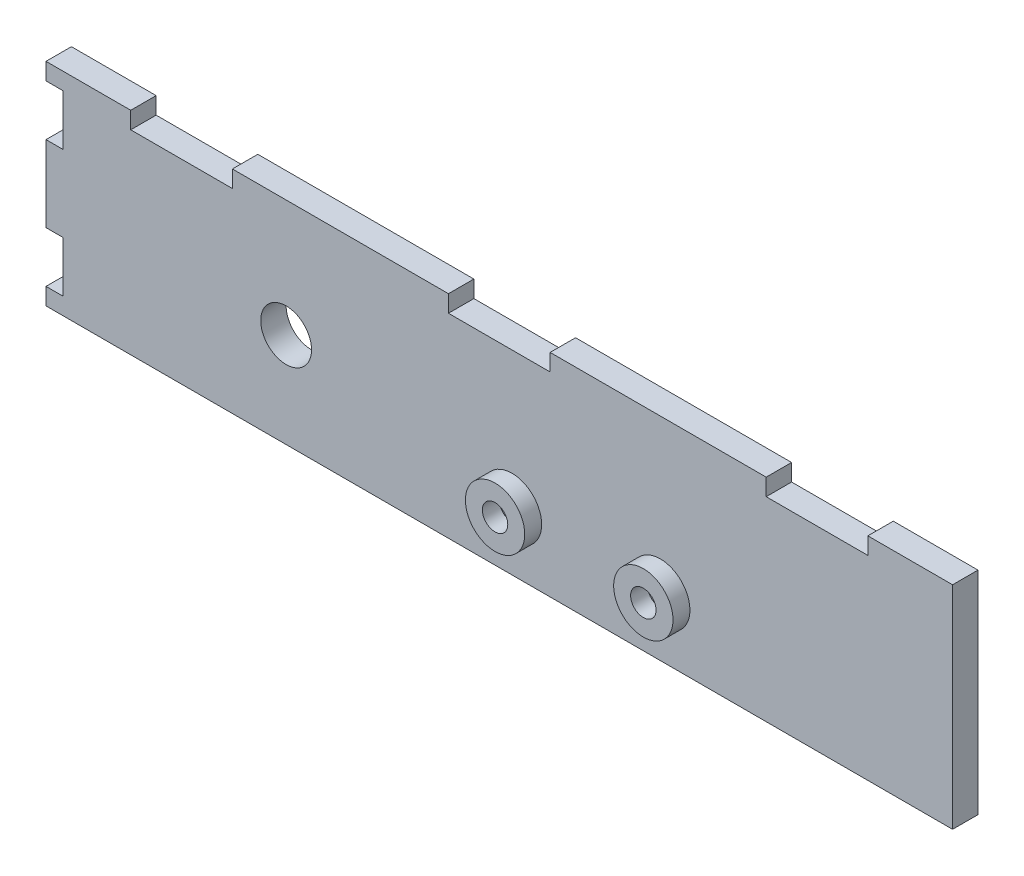
from build123d import *

# Parameters (mm, degrees)
ESBO_O1_R                = 3
ESBO_O1_R_2              = 1.5
RESSALTO_EXTRUS_O1_DEPTH = 3
ESBO_O1_19_R             = 3.5
ESBO_O1_19_R_2           = 1.5
RESSALTO_EXTRUS_O2_DEPTH = 5
ESBO_O1_20_R             = 1.5
RESSALTO_EXTRUS_O3_DEPTH = 3


with BuildPart() as part:
    # Esboço1 → Ressalto-extrusão1 (new body)
    with BuildSketch(Plane.XY):
        Polygon((-30.67768595, 33.271694215), (-40.67768595, 33.271694215), (-40.67768595, 31.271694215), (-38.67768595, 31.271694215), (-38.67768595, 25.271694215), (-40.67768595, 25.271694215), (-40.67768595, 16.271694215), (-38.67768595, 16.271694215), (-38.67768595, 10.271694215), (-40.67768595, 10.271694215), (-40.67768595, 8.271694215), (66.32231405, 8.271694215), (66.32231405, 33.271694215), (56.32231405, 33.271694215), (56.32231405, 31.271694215), (44.32231405, 31.271694215), (44.32231405, 33.271694215), (18.82231405, 33.271694215), (18.82231405, 31.271694215), (6.82231405, 31.271694215), (6.82231405, 33.271694215), (-18.67768595, 33.271694215), (-18.67768595, 31.271694215), (-30.67768595, 31.271694215), align=None)
        with Locations((-12.336122998, 19.452784517)):
            Circle(ESBO_O1_R, mode=Mode.SUBTRACT)
        with Locations((14.32231405, 15.171694215)):
            Circle(ESBO_O1_R_2, mode=Mode.SUBTRACT)
        with Locations((31.82231405, 15.171694215)):
            Circle(ESBO_O1_R_2, mode=Mode.SUBTRACT)
    extrude(amount=RESSALTO_EXTRUS_O1_DEPTH)

    # Esboço1<19> → Ressalto-extrusão2 (add)
    with BuildSketch(Plane.XY):
        with Locations((14.32231405, 15.171694215)):
            Circle(ESBO_O1_19_R)
        with Locations((14.32231405, 15.171694215)):
            Circle(ESBO_O1_19_R_2, mode=Mode.SUBTRACT)
        with Locations((31.82231405, 15.171694215)):
            Circle(ESBO_O1_19_R)
        with Locations((31.82231405, 15.171694215)):
            Circle(ESBO_O1_19_R_2, mode=Mode.SUBTRACT)
    extrude(amount=RESSALTO_EXTRUS_O2_DEPTH)

    # Esboço1<20> → Ressalto-extrusão3 (add)
    with BuildSketch(Plane.XY):
        with Locations((14.32231405, 15.171694215)):
            Circle(ESBO_O1_20_R)
        with Locations((31.82231405, 15.171694215)):
            Circle(ESBO_O1_20_R)
    extrude(amount=RESSALTO_EXTRUS_O3_DEPTH)


solid = part.part
